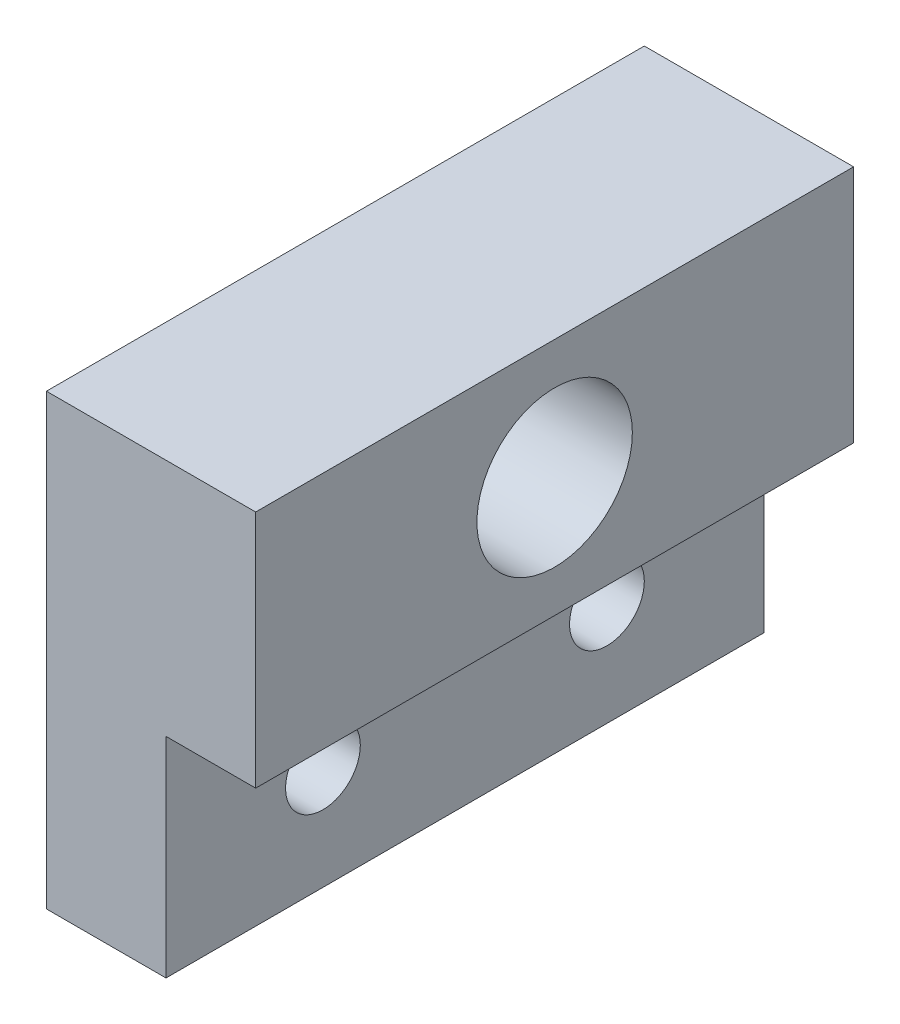
from build123d import *

# Parameters (mm, degrees)
BOSS_EXTRUDE1_DEPTH = 20
CUT_EXTRUDE1_REACH  = 9
SKETCH2_R           = 2.6
CUT_EXTRUDE2_REACH  = 6
SKETCH3_R           = 1.25


with BuildPart() as part:
    # Sketch1 → Boss-Extrude1 (new body)
    with BuildSketch(Plane.XY):
        Polygon((7, 15), (0, 15), (0, 0), (4, 0), (4, 7), (7, 7), align=None)
    extrude(amount=BOSS_EXTRUDE1_DEPTH)

    # Sketch2 → Cut-Extrude1 (cut, up to next)
    with BuildSketch(Plane(origin=(7, 0, 0), x_dir=(0, 0, -1), z_dir=(1, 0, 0)), mode=Mode.PRIVATE) as cut_extrude1_sk1:
        with Locations((-10, 11)):
            Circle(SKETCH2_R)
    cut_extrude1_tool1 = extrude(cut_extrude1_sk1.sketch, amount=-CUT_EXTRUDE1_REACH, mode=Mode.PRIVATE) & part.part
    add(cut_extrude1_tool1.solids().sort_by_distance((7, 11, 10))[0], mode=Mode.SUBTRACT)

    # Sketch3 → Cut-Extrude2 (cut, up to next)
    with BuildSketch(Plane(origin=(4, 0, 0), x_dir=(0, 0, -1), z_dir=(1, 0, 0)), mode=Mode.PRIVATE) as cut_extrude2_sk1:
        with Locations((-14.75, 3.497875885)):
            Circle(SKETCH3_R)
    cut_extrude2_tool1 = extrude(cut_extrude2_sk1.sketch, amount=-CUT_EXTRUDE2_REACH, mode=Mode.PRIVATE) & part.part
    add(cut_extrude2_tool1.solids().sort_by_distance((4, 3.497876, 14.75))[0], mode=Mode.SUBTRACT)
    # Sketch3 → Cut-Extrude2 (cut, up to next)
    with BuildSketch(Plane(origin=(4, 0, 0), x_dir=(0, 0, -1), z_dir=(1, 0, 0)), mode=Mode.PRIVATE) as cut_extrude2_sk2:
        with Locations((-5.25, 3.497875885)):
            Circle(SKETCH3_R)
    cut_extrude2_tool2 = extrude(cut_extrude2_sk2.sketch, amount=-CUT_EXTRUDE2_REACH, mode=Mode.PRIVATE) & part.part
    add(cut_extrude2_tool2.solids().sort_by_distance((4, 3.497876, 5.25))[0], mode=Mode.SUBTRACT)


solid = part.part
